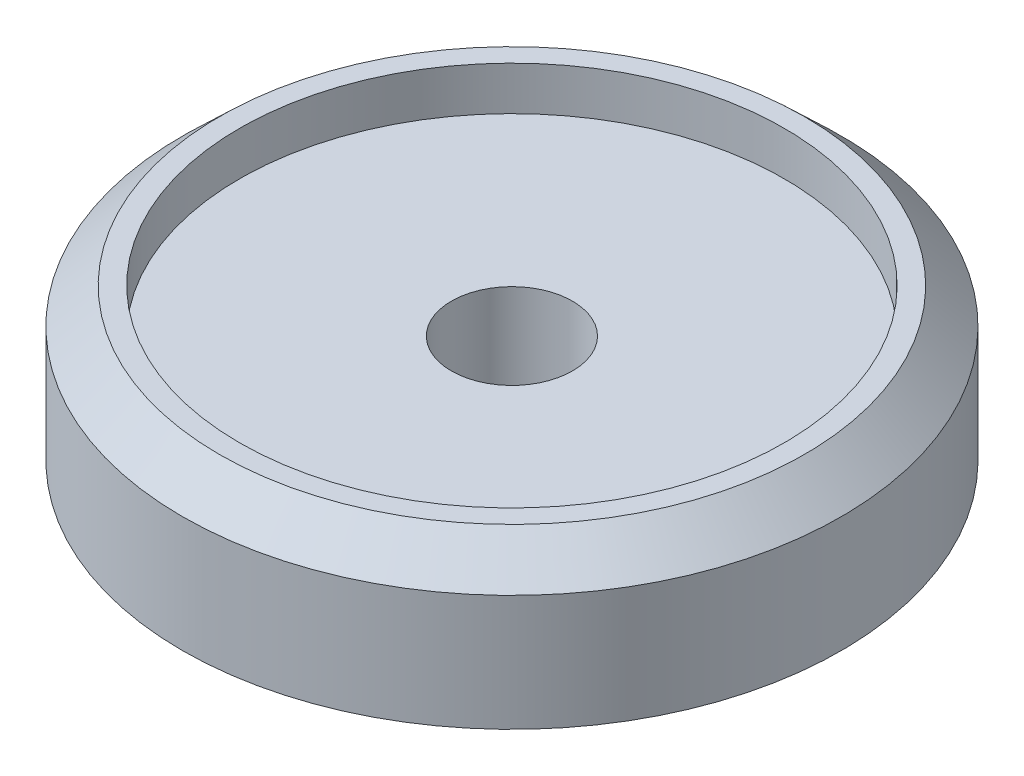
from build123d import *

# Parameters (mm, degrees)
SKETCH1_R           = 49
BOSS_EXTRUDE1_DEPTH = 16
SKETCH3_R           = 12
BOSS_EXTRUDE2_DEPTH = 25
SKETCH4_R           = 9
CUT_EXTRUDE1_DEPTH  = 42


with BuildPart() as part:
    # Sketch1 → Boss-Extrude1 (new body)
    with BuildSketch(Plane(origin=(0, 0, 0), x_dir=(1, 0, 0), z_dir=(0, 1, 0))):
        Circle(SKETCH1_R)
    extrude(amount=BOSS_EXTRUDE1_DEPTH)

    # Sketch2 → Revolve1 (revolve)
    with BuildSketch(Plane.XY):
        Polygon((-43.5, 22.5), (-40.5, 22.5), (-40.5, 16), (-49, 16), (-49, 17.25), align=None)
    revolve(axis=Axis((0, 16, 0), (0, -1, 0)))

    # Sketch3 → Boss-Extrude2 (add)
    with BuildSketch(Plane.XZ):
        Circle(SKETCH3_R)
    extrude(amount=BOSS_EXTRUDE2_DEPTH)

    # Sketch4 → Cut-Extrude1 (cut, through all)
    with BuildSketch(Plane(origin=(0, 16, 0), x_dir=(1, 0, 0), z_dir=(0, 1, 0))):
        Circle(SKETCH4_R)
    extrude(amount=-CUT_EXTRUDE1_DEPTH, mode=Mode.SUBTRACT)


solid = part.part
